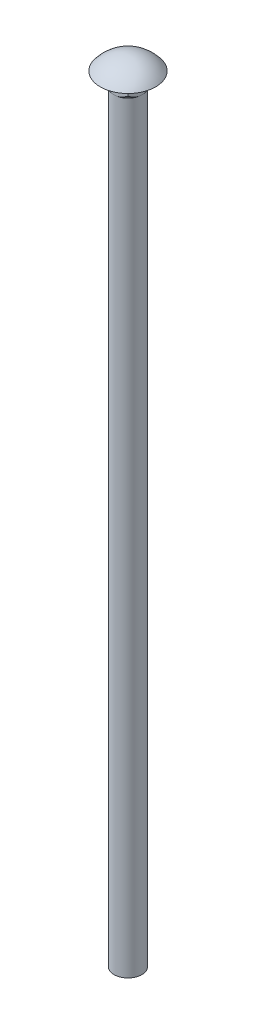
from build123d import *

# Parameters (mm, degrees)
SKETCH1_R           = 6.35
BOSS_EXTRUDE1_DEPTH = 349.25
SKETCH2_W           = 12.7
SKETCH2_H           = 12.7
BOSS_EXTRUDE2_DEPTH = 6.35
SKETCH3_R           = 12.7
BOSS_EXTRUDE3_DEPTH = 6.35
SKETCH5_OUTSIDE_W   = 112.846
SKETCH5_OUTSIDE_H   = 112.846
SKETCH5_OUTSIDE_R   = 6.35
CUT_EXTRUDE1_DEPTH  = 6.35
CUT_EXTRUDE1_TAPER  = 45


with BuildPart() as part:
    # Sketch1 → Boss-Extrude1 (new body)
    with BuildSketch(Plane(origin=(0, 0, 0), x_dir=(1, 0, 0), z_dir=(0, 1, 0))):
        Circle(SKETCH1_R)
    extrude(amount=BOSS_EXTRUDE1_DEPTH)

    # Sketch2 → Boss-Extrude2 (add)
    with BuildSketch(Plane(origin=(0, 349.25, 0), x_dir=(1, 0, 0), z_dir=(0, 1, 0))):
        Rectangle(SKETCH2_W, SKETCH2_H)
    extrude(amount=BOSS_EXTRUDE2_DEPTH)

    # Sketch3 → Boss-Extrude3 (add)
    with BuildSketch(Plane(origin=(0, 355.6, 0), x_dir=(1, 0, 0), z_dir=(0, 1, 0))):
        Circle(SKETCH3_R)
    extrude(amount=BOSS_EXTRUDE3_DEPTH)

    # Sketch4 → Cut-Revolve1 (revolve, cut)
    with BuildSketch(Plane(origin=(0, 0, 0), x_dir=(0, 0, -1), z_dir=(1, 0, 0))):
        with BuildLine():
            Line((-12.7, 355.6), (-17.199061604, 355.6))
            Line((-17.199061604, 355.6), (-17.199061604, 364.492507037))
            Line((-17.199061604, 364.492507037), (0, 364.492507037))
            Line((0, 364.492507037), (0, 361.95))
            ThreePointArc((0, 361.95), (-7.099515829, 360.274031657), (-12.7, 355.6))
        make_face()
    revolve(axis=Axis((0, 369.557753648, 0), (0, -1, 0)), mode=Mode.SUBTRACT)

    # Sketch5 outside → Cut-Extrude1 (cut)
    with BuildSketch(Plane.XZ.offset(-349.25)):
        Rectangle(SKETCH5_OUTSIDE_W, SKETCH5_OUTSIDE_H)
        Circle(SKETCH5_OUTSIDE_R, mode=Mode.SUBTRACT)
    extrude(amount=-CUT_EXTRUDE1_DEPTH, taper=CUT_EXTRUDE1_TAPER, mode=Mode.SUBTRACT)


solid = part.part
